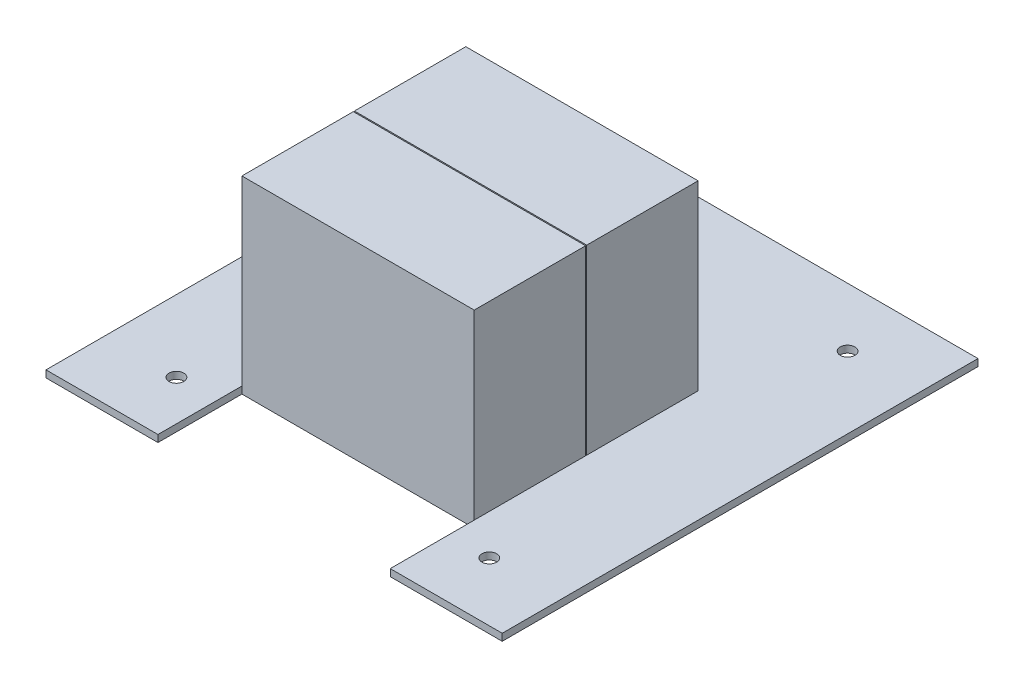
from build123d import *

# Parameters (mm, degrees)
SALIENTE_EXTRUIR1_DEPTH = 2.5
CROQUIS2_W              = 83
CROQUIS2_H              = 80
SALIENTE_EXTRUIR2_DEPTH = 65
CORTAR_EXTRUIR1_DEPTH   = 71
CROQUIS4_R              = 2.625
CORTAR_EXTRUIR2_DEPTH   = 68.5


with BuildPart() as part:
    # Croquis1 → Saliente-Extruir1 (new body)
    with BuildSketch(Plane(origin=(0, 0, 0), x_dir=(1, 0, 0), z_dir=(0, 1, 0))):
        Polygon((41.5, -85), (81.5, -85), (81.5, 85), (-81.5, 85), (-81.5, -85), (-41.5, -85), (-41.5, -55), (41.5, -55), align=None)
    extrude(amount=SALIENTE_EXTRUIR1_DEPTH)

    # Croquis2 → Saliente-Extruir2 (add)
    with BuildSketch(Plane(origin=(0, 2.5, 0), x_dir=(1, 0, 0), z_dir=(0, 1, 0))):
        with Locations((0, -15)):
            Rectangle(CROQUIS2_W, CROQUIS2_H)
    extrude(amount=SALIENTE_EXTRUIR2_DEPTH)

    # Croquis3 → Cortar-Extruir1 (cut, through all)
    with BuildSketch(Plane(origin=(0, 70, 0), x_dir=(1, 0, 0), z_dir=(0, 1, 0))):
        Polygon((-41.5, -15), (-41.5, -14.8), (41.5, -14.8), (41.5, -15.2), (-41.5, -15.2), align=None)
    extrude(amount=-CORTAR_EXTRUIR1_DEPTH, mode=Mode.SUBTRACT)

    # Croquis4 → Cortar-Extruir2 (cut, through all)
    with BuildSketch(Plane(origin=(0, 0, 0), x_dir=(1, 0, 0), z_dir=(0, 1, 0))):
        with Locations((-55.9, -64)):
            Circle(CROQUIS4_R)
        with Locations((55.9, -64)):
            Circle(CROQUIS4_R)
        with Locations((-55.9, 64)):
            Circle(CROQUIS4_R)
        with Locations((55.9, 64)):
            Circle(CROQUIS4_R)
    extrude(amount=CORTAR_EXTRUIR2_DEPTH, mode=Mode.SUBTRACT)


solid = part.part
